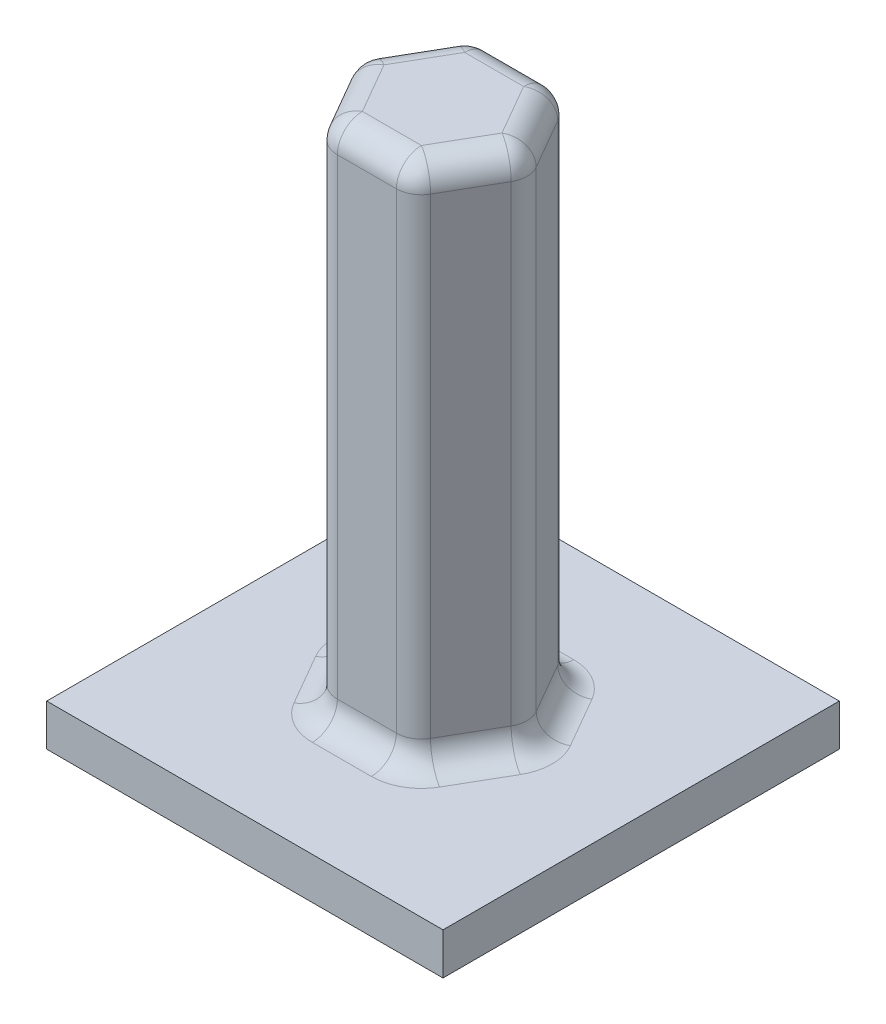
from build123d import *

# Parameters (mm, degrees)
CROQUIS1_W              = 19
CROQUIS1_H              = 19
SALIENTE_EXTRUIR1_DEPTH = 2
SALIENTE_EXTRUIR2_DEPTH = 25
REDONDEO1_R             = 1.2


with BuildPart() as part:
    # Croquis1 → Saliente-Extruir1 (new body)
    with BuildSketch(Plane(origin=(0, 0, 0), x_dir=(1, 0, 0), z_dir=(0, 1, 0))):
        Rectangle(CROQUIS1_W, CROQUIS1_H)
    extrude(amount=SALIENTE_EXTRUIR1_DEPTH)

    # Croquis2 → Saliente-Extruir2 (add)
    with BuildSketch(Plane(origin=(0, 2, 0), x_dir=(1, 0, 0), z_dir=(0, 1, 0))):
        Polygon((4.214656965, 0), (2.107328483, 3.65), (-2.107328483, 3.65), (-4.214656965, 0), (-2.107328483, -3.65), (2.107328483, -3.65), align=None)
    extrude(amount=SALIENTE_EXTRUIR2_DEPTH)

    # Redondeo1
    redondeo1_edges = [part.edges().sort_by_distance(p)[0] for p in [
        (3.160992724, 2, 1.825),
        (2.107328483, 14.5, 3.65),
        (3.160992724, 2, -1.825),
        (4.214656965, 14.5, 0),
        (0, 2, -3.65),
        (2.107328483, 14.5, -3.65),
        (-3.160992724, 2, -1.825),
        (-2.107328483, 14.5, -3.65),
        (-3.160992724, 2, 1.825),
        (-4.214656965, 14.5, 0),
        (0, 2, 3.65),
        (-2.107328483, 14.5, 3.65),
        (3.160992724, 27, 1.825),
        (3.160992724, 27, -1.825),
        (0, 27, -3.65),
        (-3.160992724, 27, -1.825),
        (-3.160992724, 27, 1.825),
        (0, 27, 3.65),
    ]]
    fillet(redondeo1_edges, radius=REDONDEO1_R)


solid = part.part
